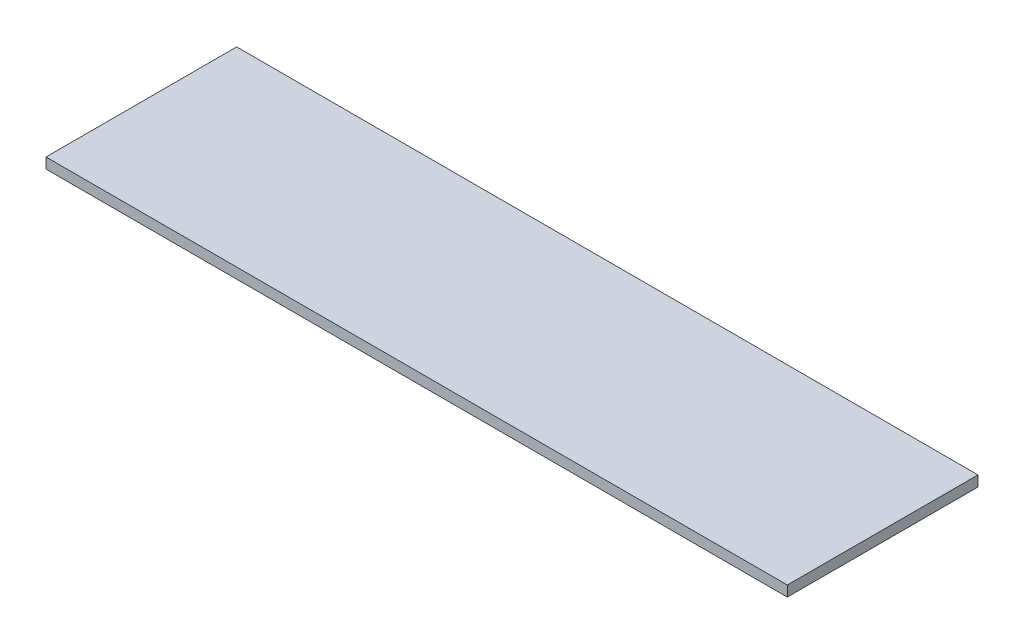
from build123d import *

# Parameters (mm, degrees)
ESQUISSE1_W        = 141.161319704
ESQUISSE1_H        = 36.307642768
BOSS_EXTRU_1_DEPTH = 2


with BuildPart() as part:
    # Esquisse1 → Boss.-Extru.1 (new body)
    with BuildSketch(Plane(origin=(0, 0, 0), x_dir=(1, 0, 0), z_dir=(0, 1, 0))):
        with Locations((70.580659852, 18.153821384)):
            Rectangle(ESQUISSE1_W, ESQUISSE1_H)
    extrude(amount=BOSS_EXTRU_1_DEPTH)


solid = part.part
